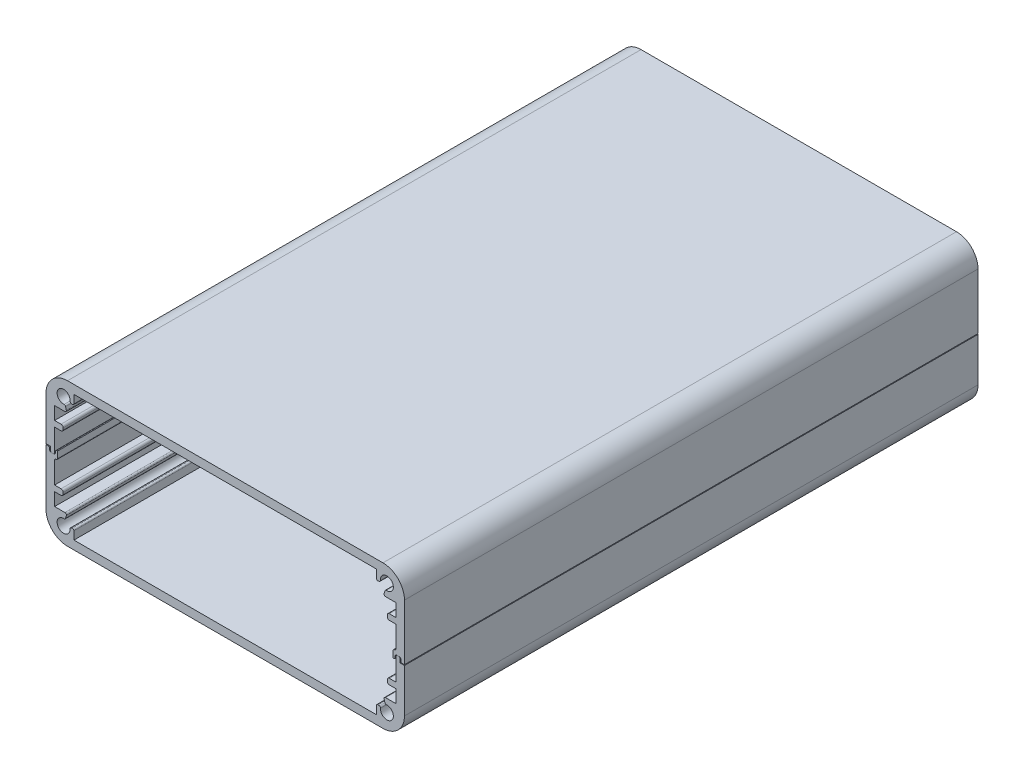
from build123d import *

# Parameters (mm, degrees)
EXTRUDE_1_DEPTH = 80
EXTRUDE_2_DEPTH = 80


with BuildPart() as part:
    # 草图5 → 凸台-拉伸1 (new body)
    with BuildSketch(Plane.XY):
        with BuildLine():
            Line((-2.45, 14.8), (-2.45, 8.7))
            Line((-2.45, 8.7), (-1.85, 8.7))
            Line((-1.85, 8.7), (-1.85, 8.2))
            ThreePointArc((-1.85, 8.2), (-1.791421356, 8.058578644), (-1.65, 8))
            Line((-1.65, 8), (-1.45, 8))
            ThreePointArc((-1.45, 8), (-1.308578644, 8.058578644), (-1.25, 8.2))
            Line((-1.25, 8.2), (-1.25, 11.3))
            Line((-1.25, 11.3), (-0.35, 11.3))
            ThreePointArc((-0.35, 11.3), (-0.137867966, 11.387867966), (-0.05, 11.6))
            Line((-0.05, 11.6), (-0.05, 11.8))
            ThreePointArc((-0.05, 11.8), (-0.137867966, 12.012132034), (-0.35, 12.1))
            Line((-0.35, 12.1), (-1.25, 12.1))
            Line((-1.25, 12.1), (-1.25, 13.9))
            Line((-1.25, 13.9), (0.194868553, 13.9))
            ThreePointArc((0.194868553, 13.9), (0.353539221, 13.978247714), (0.388053718, 14.151763809))
            Line((0.388053718, 14.151763809), (0.279955601, 14.555191472))
            ThreePointArc((0.279955601, 14.555191472), (0.202164811, 14.666780466), (0.070993993, 14.702804451))
            ThreePointArc((0.070993993, 14.702804451), (-0.636396103, 16.236396103), (0.897195549, 15.529006007))
            ThreePointArc((0.897195549, 15.529006007), (0.933219534, 15.397835189), (1.044808528, 15.320044399))
            Line((1.044808528, 15.320044399), (1.198236191, 15.27893358))
            ThreePointArc((1.198236191, 15.27893358), (1.371752286, 15.313448077), (1.45, 15.472118746))
            Line((1.45, 15.472118746), (1.45, 16.6))
            Line((1.45, 16.6), (43.65, 16.6))
            Line((43.65, 16.6), (43.65, 15.472118746))
            ThreePointArc((43.65, 15.472118746), (43.728247714, 15.313448077), (43.901763809, 15.27893358))
            Line((43.901763809, 15.27893358), (44.055191471, 15.320044399))
            ThreePointArc((44.055191471, 15.320044399), (44.166780466, 15.397835189), (44.202804451, 15.529006007))
            ThreePointArc((44.202804451, 15.529006007), (45.736396103, 16.236396103), (45.029006007, 14.702804451))
            ThreePointArc((45.029006007, 14.702804451), (44.897835189, 14.666780466), (44.820044399, 14.555191472))
            Line((44.820044399, 14.555191472), (44.711946282, 14.151763809))
            ThreePointArc((44.711946282, 14.151763809), (44.746460779, 13.978247714), (44.905131447, 13.9))
            Line((44.905131447, 13.9), (46.35, 13.9))
            Line((46.35, 13.9), (46.35, 12.1))
            Line((46.35, 12.1), (45.45, 12.1))
            ThreePointArc((45.45, 12.1), (45.237867966, 12.012132034), (45.15, 11.8))
            Line((45.15, 11.8), (45.15, 11.6))
            ThreePointArc((45.15, 11.6), (45.237867966, 11.387867966), (45.45, 11.3))
            Line((45.45, 11.3), (46.35, 11.3))
            Line((46.35, 11.3), (46.35, 8.3))
            ThreePointArc((46.35, 8.3), (46.291421356, 8.158578644), (46.15, 8.1))
            ThreePointArc((46.15, 8.1), (46.008578644, 8.041421356), (45.95, 7.9))
            Line((45.95, 7.9), (45.95, 7))
            Line((45.95, 7), (46.05, 7))
            ThreePointArc((46.05, 7), (46.191421356, 7.058578644), (46.25, 7.2))
            Line((46.25, 7.2), (46.25, 7.4))
            ThreePointArc((46.25, 7.4), (46.308578644, 7.541421356), (46.45, 7.6))
            Line((46.45, 7.6), (46.85, 7.6))
            ThreePointArc((46.85, 7.6), (46.991421356, 7.541421356), (47.05, 7.4))
            Line((47.05, 7.4), (47.05, 7.2))
            ThreePointArc((47.05, 7.2), (47.108578644, 7.058578644), (47.25, 7))
            Line((47.25, 7), (47.55, 7))
            Line((47.55, 7), (47.55, 14.8))
            ThreePointArc((47.55, 14.8), (46.671320344, 16.921320344), (44.55, 17.8))
            Line((44.55, 17.8), (0.55, 17.8))
            ThreePointArc((0.55, 17.8), (-1.571320344, 16.921320344), (-2.45, 14.8))
        make_face()
    extrude(amount=EXTRUDE_1_DEPTH)


with BuildPart() as body_2:
    # 草图5<3> → 凸台-拉伸2 (new body)
    with BuildSketch(Plane.XY):
        with BuildLine():
            Line((47.55, 0.8), (47.55, 6.9))
            Line((47.55, 6.9), (46.95, 6.9))
            Line((46.95, 6.9), (46.95, 7.4))
            ThreePointArc((46.95, 7.4), (46.891421356, 7.541421356), (46.75, 7.6))
            Line((46.75, 7.6), (46.55, 7.6))
            ThreePointArc((46.55, 7.6), (46.408578644, 7.541421356), (46.35, 7.4))
            Line((46.35, 7.4), (46.35, 4.3))
            Line((46.35, 4.3), (45.45, 4.3))
            ThreePointArc((45.45, 4.3), (45.237867966, 4.212132034), (45.15, 4))
            Line((45.15, 4), (45.15, 3.8))
            ThreePointArc((45.15, 3.8), (45.237867966, 3.587867966), (45.45, 3.5))
            Line((45.45, 3.5), (46.35, 3.5))
            Line((46.35, 3.5), (46.35, 1.7))
            Line((46.35, 1.7), (44.905131447, 1.7))
            ThreePointArc((44.905131447, 1.7), (44.746460779, 1.621752286), (44.711946282, 1.448236191))
            Line((44.711946282, 1.448236191), (44.820044399, 1.044808528))
            ThreePointArc((44.820044399, 1.044808528), (44.897835189, 0.933219534), (45.029006007, 0.897195549))
            ThreePointArc((45.029006007, 0.897195549), (45.736396103, -0.636396103), (44.202804451, 0.070993993))
            ThreePointArc((44.202804451, 0.070993993), (44.166780466, 0.202164811), (44.055191471, 0.279955601))
            Line((44.055191471, 0.279955601), (43.901763809, 0.32106642))
            ThreePointArc((43.901763809, 0.32106642), (43.728247714, 0.286551923), (43.65, 0.127881254))
            Line((43.65, 0.127881254), (43.65, -1))
            Line((43.65, -1), (1.45, -1))
            Line((1.45, -1), (1.45, 0.127881254))
            ThreePointArc((1.45, 0.127881254), (1.371752286, 0.286551923), (1.198236191, 0.32106642))
            Line((1.198236191, 0.32106642), (1.044808528, 0.279955601))
            ThreePointArc((1.044808528, 0.279955601), (0.933219534, 0.202164811), (0.897195549, 0.070993993))
            ThreePointArc((0.897195549, 0.070993993), (-0.636396103, -0.636396103), (0.070993993, 0.897195549))
            ThreePointArc((0.070993993, 0.897195549), (0.202164811, 0.933219534), (0.279955601, 1.044808528))
            Line((0.279955601, 1.044808528), (0.388053718, 1.448236191))
            ThreePointArc((0.388053718, 1.448236191), (0.353539221, 1.621752286), (0.194868553, 1.7))
            Line((0.194868553, 1.7), (-1.25, 1.7))
            Line((-1.25, 1.7), (-1.25, 3.5))
            Line((-1.25, 3.5), (-0.35, 3.5))
            ThreePointArc((-0.35, 3.5), (-0.137867966, 3.587867966), (-0.05, 3.8))
            Line((-0.05, 3.8), (-0.05, 4))
            ThreePointArc((-0.05, 4), (-0.137867966, 4.212132034), (-0.35, 4.3))
            Line((-0.35, 4.3), (-1.25, 4.3))
            Line((-1.25, 4.3), (-1.25, 7.3))
            ThreePointArc((-1.25, 7.3), (-1.191421356, 7.441421356), (-1.05, 7.5))
            ThreePointArc((-1.05, 7.5), (-0.908578644, 7.558578644), (-0.85, 7.7))
            Line((-0.85, 7.7), (-0.85, 8.6))
            Line((-0.85, 8.6), (-0.95, 8.6))
            ThreePointArc((-0.95, 8.6), (-1.091421356, 8.541421356), (-1.15, 8.4))
            Line((-1.15, 8.4), (-1.15, 8.2))
            ThreePointArc((-1.15, 8.2), (-1.208578644, 8.058578644), (-1.35, 8))
            Line((-1.35, 8), (-1.75, 8))
            ThreePointArc((-1.75, 8), (-1.891421356, 8.058578644), (-1.95, 8.2))
            Line((-1.95, 8.2), (-1.95, 8.4))
            ThreePointArc((-1.95, 8.4), (-2.008578644, 8.541421356), (-2.15, 8.6))
            Line((-2.15, 8.6), (-2.45, 8.6))
            Line((-2.45, 8.6), (-2.45, 0.8))
            ThreePointArc((-2.45, 0.8), (-1.571320344, -1.321320344), (0.55, -2.2))
            Line((0.55, -2.2), (44.55, -2.2))
            ThreePointArc((44.55, -2.2), (46.671320344, -1.321320344), (47.55, 0.8))
        make_face()
    extrude(amount=EXTRUDE_2_DEPTH)


solid = Compound([part.part, body_2.part])
